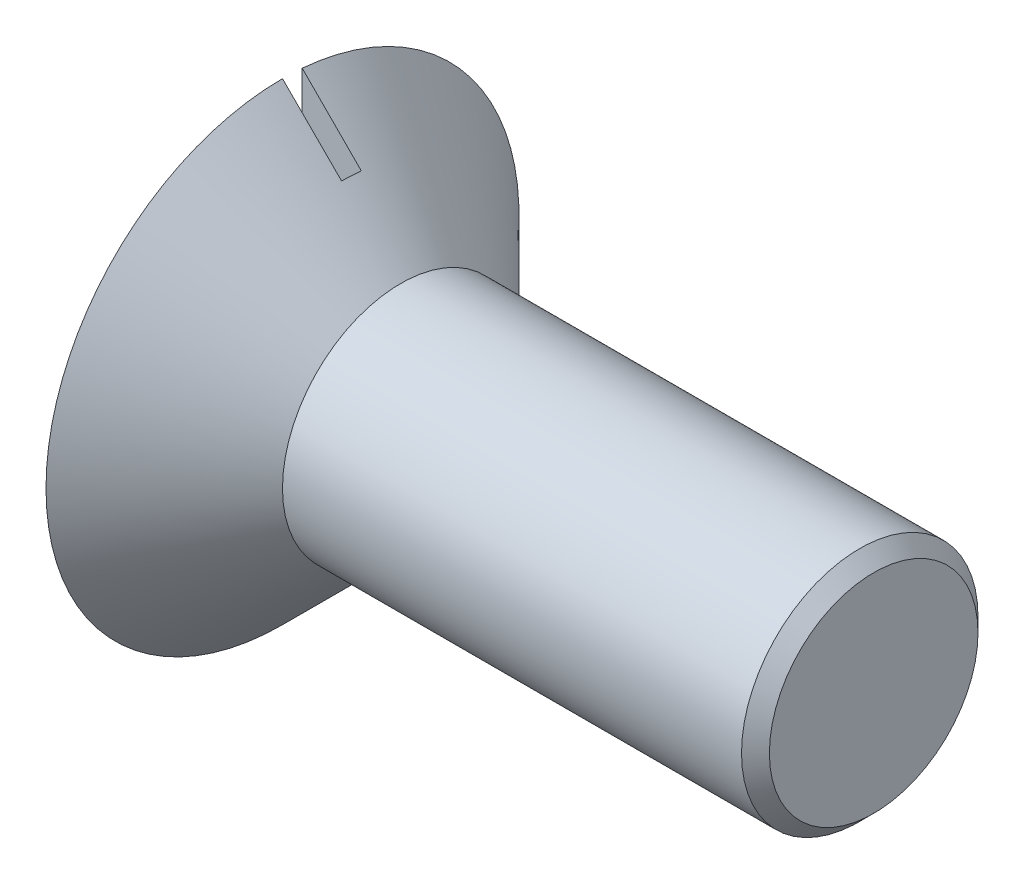
from build123d import *

# Parameters (mm, degrees)
SKETCH3_W          = 3
SKETCH3_H          = 1.001019848
CUT_EXTRUDE1_DEPTH = 50


with BuildPart() as part:
    # Sketch2 → Revolve1 (revolve)
    with BuildSketch(Plane.XY):
        Polygon((10.441459651, 6), (25.219960982, 6), (33.73435287, 6), (34.441459651, 5.292893219), (34.441459651, 2.788575112), (34.441459651, 0), (4.441459651, 0), (4.441459651, 12), align=None)
    revolve(axis=Axis((-22.000325263, 0, 0), (1, 0, 0)))

    # Sketch3 → Cut-Extrude1 (cut, symmetric)
    with BuildSketch(Plane(origin=(0, 0, 0), x_dir=(1, 0, 0), z_dir=(0, 1, 0))):
        with Locations((5.941459651, 0.500509924)):
            Rectangle(SKETCH3_W, SKETCH3_H)
    extrude(amount=CUT_EXTRUDE1_DEPTH, both=True, mode=Mode.SUBTRACT)


solid = part.part
